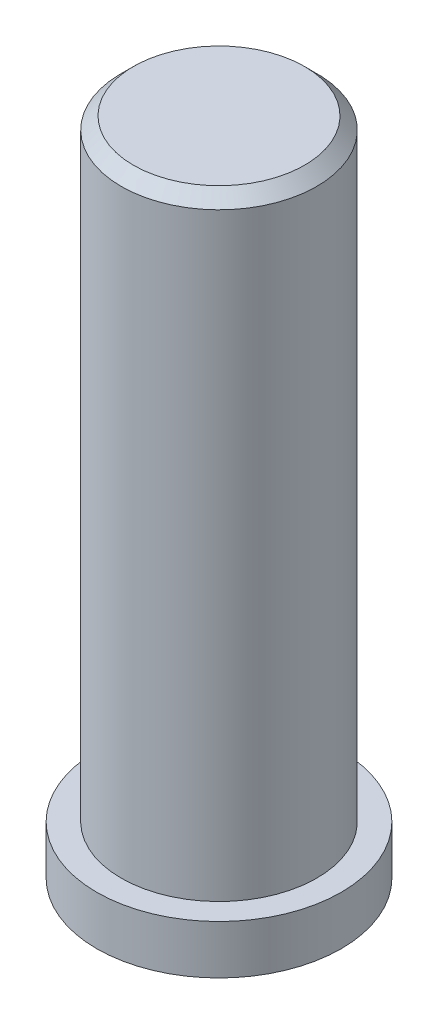
from build123d import *

# Parameters (mm, degrees)
SKETCH1_R           = 5
BOSS_EXTRUDE1_DEPTH = 2
SKETCH2_R           = 4
BOSS_EXTRUDE2_DEPTH = 25
CHAMFER1_SIZE       = 0.5


with BuildPart() as part:
    # Sketch1 → Boss-Extrude1 (new body)
    with BuildSketch(Plane(origin=(0, 0, 0), x_dir=(1, 0, 0), z_dir=(0, 1, 0))):
        Circle(SKETCH1_R)
    extrude(amount=BOSS_EXTRUDE1_DEPTH)

    # Sketch2 → Boss-Extrude2 (add)
    with BuildSketch(Plane(origin=(0, 2, 0), x_dir=(1, 0, 0), z_dir=(0, 1, 0))):
        Circle(SKETCH2_R)
    extrude(amount=BOSS_EXTRUDE2_DEPTH)

    # Chamfer1
    chamfer1_edges = [part.edges().sort_by_distance(p)[0] for p in [
        (-4, 27, 0),
    ]]
    chamfer(chamfer1_edges, length=CHAMFER1_SIZE)


solid = part.part
